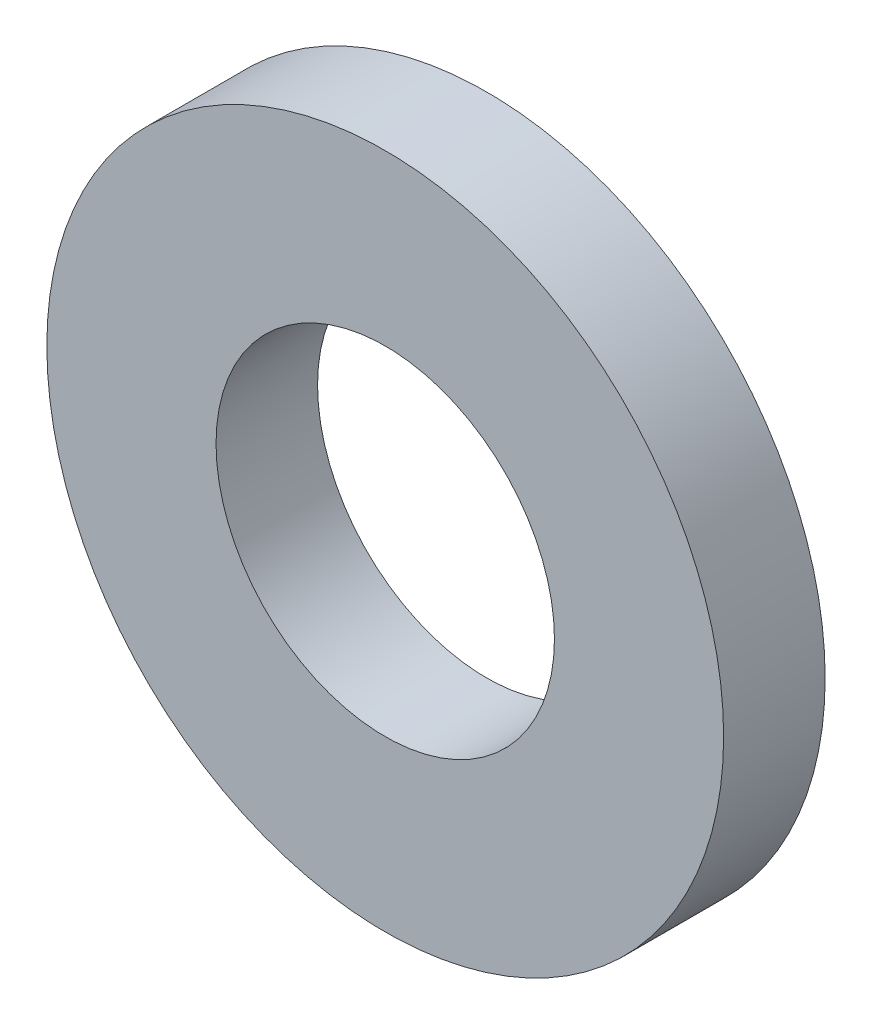
from build123d import *

# Parameters (mm, degrees)
SKETCH1_R           = 3
SKETCH1_R_2         = 1.5
BOSS_EXTRUDE1_DEPTH = 0.9


with BuildPart() as part:
    # Sketch1 → Boss-Extrude1 (new body)
    with BuildSketch(Plane.XY):
        Circle(SKETCH1_R)
        Circle(SKETCH1_R_2, mode=Mode.SUBTRACT)
    extrude(amount=BOSS_EXTRUDE1_DEPTH)


solid = part.part
